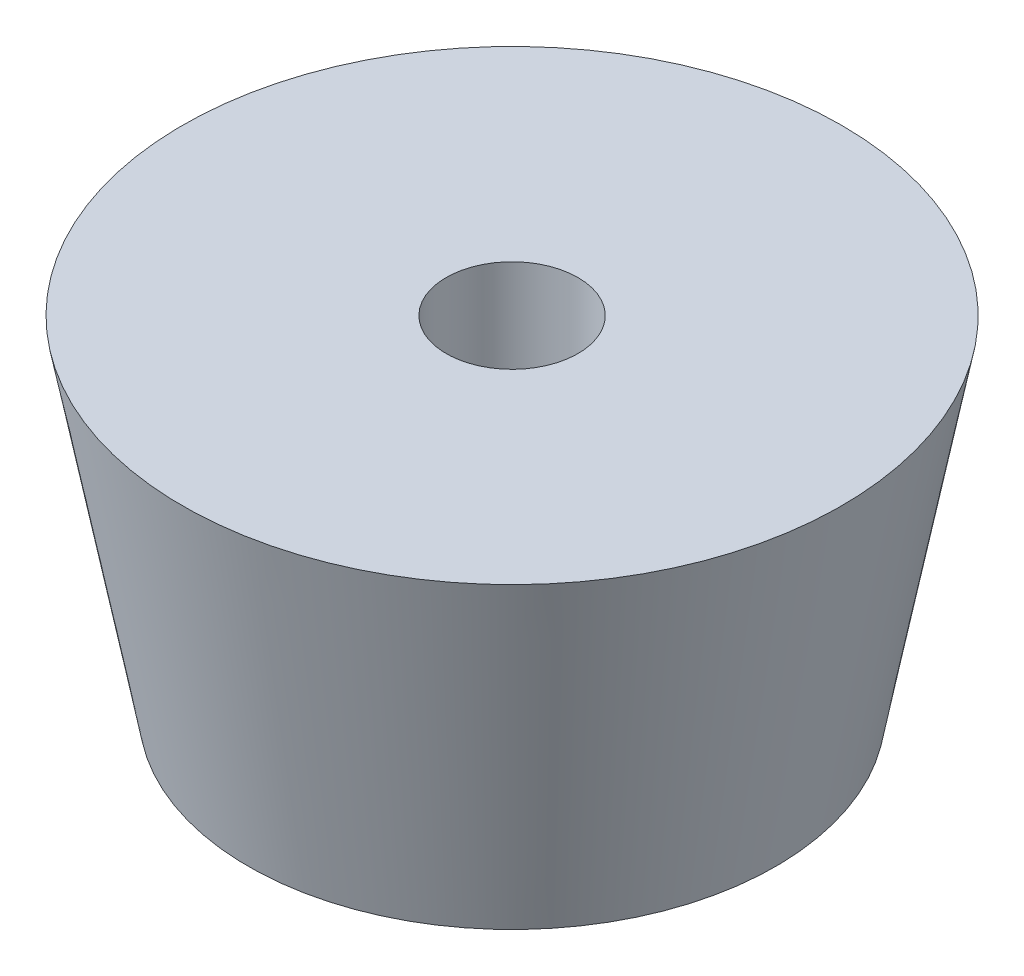
from build123d import *

# Parameters (mm, degrees)
SKETCH3_R          = 1.5
CUT_EXTRUDE1_DEPTH = 8.858116823
SKETCH4_R          = 3.5
CUT_EXTRUDE2_DEPTH = 5


with BuildPart() as part:
    # Sketch2 → Revolve1 (revolve)
    with BuildSketch(Plane.XY):
        Polygon((0, 0), (6, 0), (7.5, 7.858116823), (0, 7.858116823), align=None)
    revolve(axis=Axis((0, 0, 0), (0, 1, 0)))

    # Sketch3 → Cut-Extrude1 (cut, through all)
    with BuildSketch(Plane(origin=(0, 0, 0), x_dir=(-1, 0, 0), z_dir=(0, -1, 0))):
        Circle(SKETCH3_R)
    extrude(amount=-CUT_EXTRUDE1_DEPTH, mode=Mode.SUBTRACT)

    # Sketch4 → Cut-Extrude2 (cut)
    with BuildSketch(Plane(origin=(0, 0, 0), x_dir=(-1, 0, 0), z_dir=(0, -1, 0))):
        Circle(SKETCH4_R)
    extrude(amount=-CUT_EXTRUDE2_DEPTH, mode=Mode.SUBTRACT)


solid = part.part
